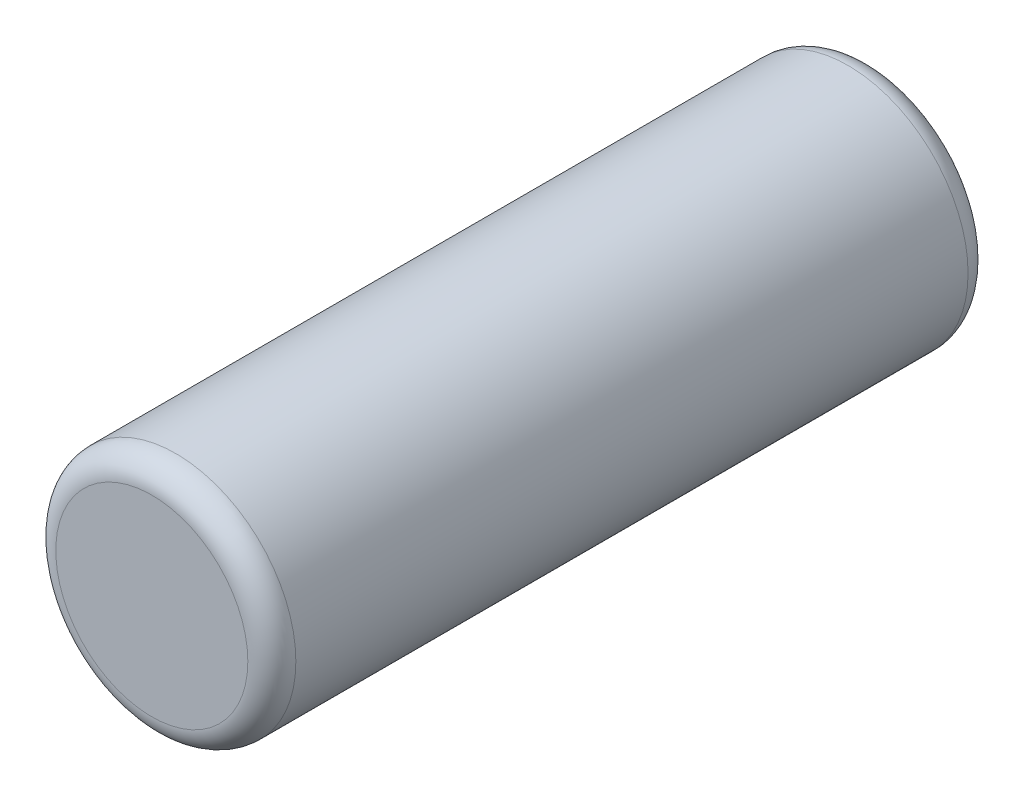
from build123d import *

# Parameters (mm, degrees)
SKETCH1_R           = 2.5
BOSS_EXTRUDE1_DEPTH = 15
FILLET1_R           = 0.5


with BuildPart() as part:
    # Sketch1 → Boss-Extrude1 (new body)
    with BuildSketch(Plane.XY):
        Circle(SKETCH1_R)
    extrude(amount=BOSS_EXTRUDE1_DEPTH)

    # Fillet1
    fillet1_edges = [part.edges().sort_by_distance(p)[0] for p in [
        (-2.5, 0, 0),
        (-2.5, 0, 15),
    ]]
    fillet(fillet1_edges, radius=FILLET1_R)


solid = part.part
